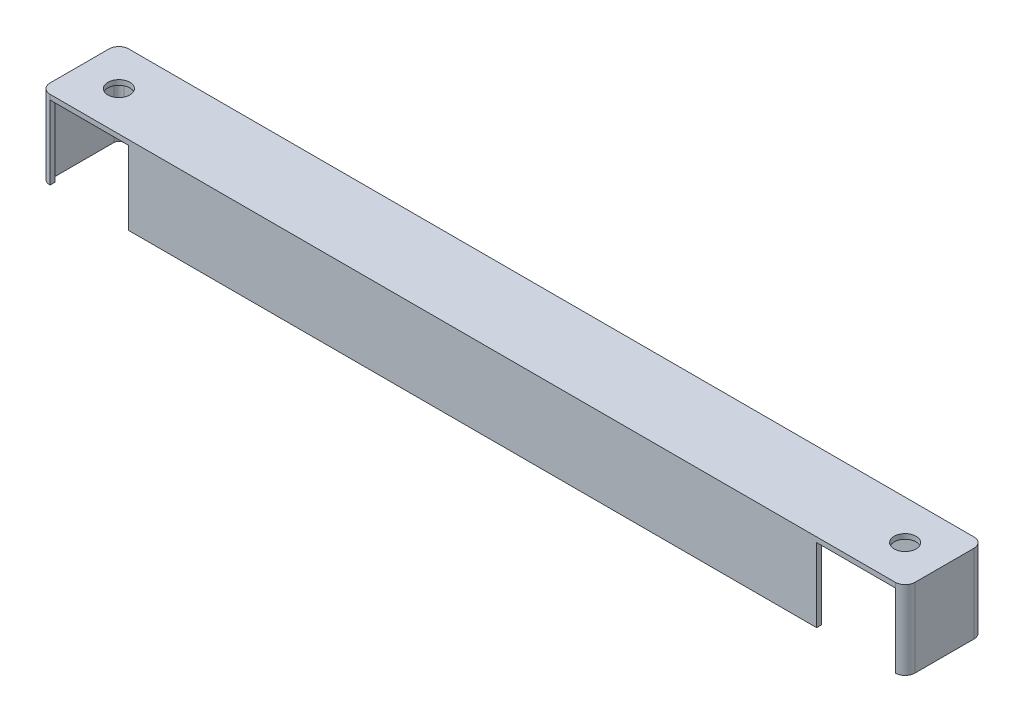
from build123d import *

# Parameters (mm, degrees)
SKETCH1_R           = 3.556
BOSS_EXTRUDE3_DEPTH = 25.4
CUT_EXTRUDE3_DEPTH  = 23.8125


with BuildPart() as part:
    # Sketch1 → Boss-Extrude3 (new body)
    with BuildSketch(Plane(origin=(0, 0, 0), x_dir=(1, 0, 0), z_dir=(0, 1, 0))):
        with BuildLine():
            Line((-136.525, -12.7), (136.525, -12.7))
            ThreePointArc((136.525, -12.7), (138.77006403, -11.77006403), (139.7, -9.525))
            Line((139.7, -9.525), (139.7, 9.525))
            ThreePointArc((139.7, 9.525), (138.77006403, 11.77006403), (136.525, 12.7))
            Line((136.525, 12.7), (-136.525, 12.7))
            ThreePointArc((-136.525, 12.7), (-138.77006403, 11.77006403), (-139.7, 9.525))
            Line((-139.7, 9.525), (-139.7, -9.525))
            ThreePointArc((-139.7, -9.525), (-138.77006403, -11.77006403), (-136.525, -12.7))
        make_face()
        with Locations((127, 0)):
            Circle(SKETCH1_R, mode=Mode.SUBTRACT)
        with Locations((-127, 0)):
            Circle(SKETCH1_R, mode=Mode.SUBTRACT)
    extrude(amount=BOSS_EXTRUDE3_DEPTH)

    # Sketch5 → Cut-Extrude3 (cut)
    with BuildSketch(Plane.XZ):
        with BuildLine():
            Line((-136.525, 11.1125), (-136.525, 12.7))
            Line((-136.525, 12.7), (-111.125, 12.7))
            Line((-111.125, 12.7), (-111.125, 11.1125))
            Line((-111.125, 11.1125), (111.125, 11.1125))
            Line((111.125, 11.1125), (111.125, 12.7))
            Line((111.125, 12.7), (136.525, 12.7))
            Line((136.525, 12.7), (136.525, 11.1125))
            ThreePointArc((136.525, 11.1125), (137.647532015, 10.647532015), (138.1125, 9.525))
            Line((138.1125, 9.525), (138.1125, -9.525))
            ThreePointArc((138.1125, -9.525), (137.647532015, -10.647532015), (136.525, -11.1125))
            Line((136.525, -11.1125), (-136.525, -11.1125))
            ThreePointArc((-136.525, -11.1125), (-137.647532015, -10.647532015), (-138.1125, -9.525))
            Line((-138.1125, -9.525), (-138.1125, 9.525))
            ThreePointArc((-138.1125, 9.525), (-137.647532015, 10.647532015), (-136.525, 11.1125))
        make_face()
    extrude(amount=-CUT_EXTRUDE3_DEPTH, mode=Mode.SUBTRACT)


solid = part.part
